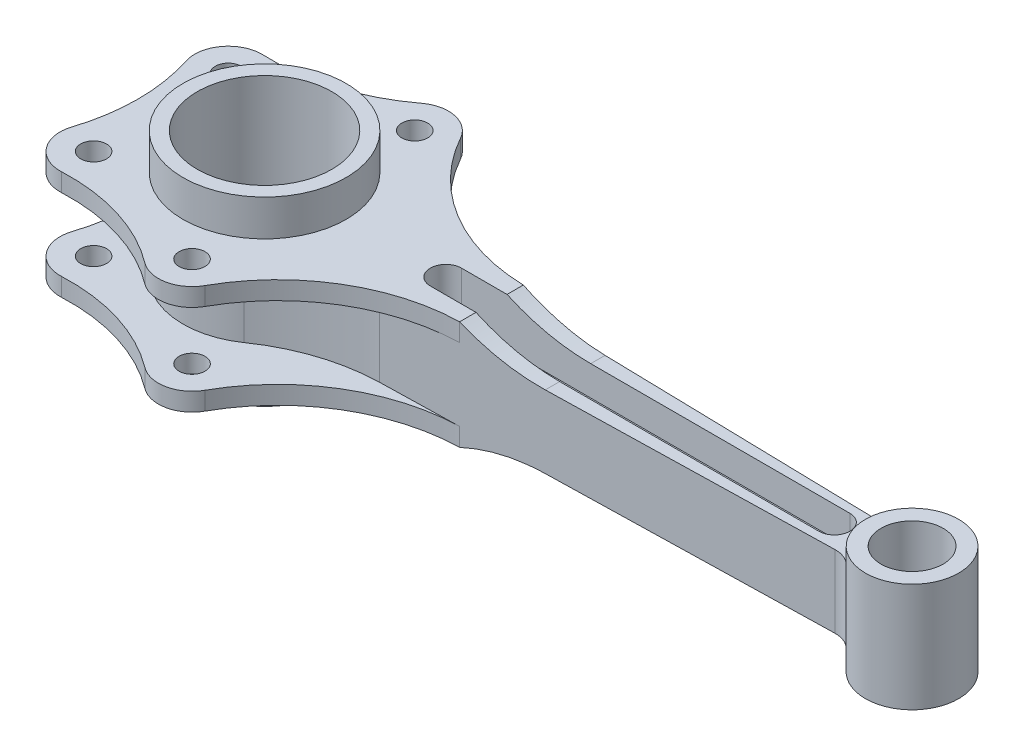
from build123d import *

# Parameters (mm, degrees)
SKETCH1_R           = 31.5
SKETCH1_R_2         = 26
BOSS_EXTRUDE1_DEPTH = 35
SKETCH1_3_R         = 18
SKETCH1_3_R_2       = 12
BOSS_EXTRUDE2_DEPTH = 21
BOSS_EXTRUDE3_DEPTH = 17.5
BOSS_EXTRUDE4_DEPTH = 14
SKETCH3_R           = 5
BOSS_EXTRUDE5_DEPTH = 7
BOSS_EXTRUDE6_REACH = 58
BOSS_EXTRUDE9_REACH = 58
SKETCH6_R           = 26
CUT_EXTRUDE1_DEPTH  = 42
CUT_EXTRUDE2_DEPTH  = 23


with BuildPart() as part:
    # Sketch1 → Boss-Extrude1 (new body, symmetric)
    with BuildSketch(Plane(origin=(0, 0, 0), x_dir=(1, 0, 0), z_dir=(0, 1, 0))):
        Circle(SKETCH1_R)
        Circle(SKETCH1_R_2, mode=Mode.SUBTRACT)
    extrude(amount=BOSS_EXTRUDE1_DEPTH, both=True)

    # Sketch1_5 → Boss-Extrude3 (add, symmetric)
    with BuildSketch(Plane(origin=(0, 0, 0), x_dir=(1, 0, 0), z_dir=(0, 1, 0))):
        with BuildLine():
            ThreePointArc((17.981178031, -25.863627677), (36.746938107, -16.532049941), (57.405028955, -13))
            Line((57.405028955, -13), (87, -12.310914466))
            Line((87, -12.310914466), (87, 12.310914466))
            Line((87, 12.310914466), (57.405028955, 13))
            ThreePointArc((57.405028955, 13), (36.746938107, 16.532049941), (17.981178031, 25.863627677))
            ThreePointArc((17.981178031, 25.863627677), (27.916456688, 14.591828056), (31.5, 0))
            ThreePointArc((31.5, 0), (27.916456688, -14.591828056), (17.981178031, -25.863627677))
        make_face()
    extrude(amount=BOSS_EXTRUDE3_DEPTH, both=True)



with BuildPart() as body_2:
    # Sketch1_3 → Boss-Extrude2 (new body, symmetric)
    with BuildSketch(Plane(origin=(0, 0, 0), x_dir=(1, 0, 0), z_dir=(0, 1, 0))):
        with Locations((250, 0)):
            Circle(SKETCH1_3_R)
        with Locations((250, 0)):
            Circle(SKETCH1_3_R_2, mode=Mode.SUBTRACT)
    extrude(amount=BOSS_EXTRUDE2_DEPTH, both=True)


with BuildPart() as part_1:
    add(part.part)

    add(body_2.part)  # Boss-Extrude4 merges body 2
    # Sketch1_6 → Boss-Extrude4 (add, symmetric)
    with BuildSketch(Plane(origin=(0, 0, 0), x_dir=(1, 0, 0), z_dir=(0, 1, 0))):
        with BuildLine():
            Line((87, 12.310914466), (87, -12.310914466))
            Line((87, -12.310914466), (229.197757742, -9))
            ThreePointArc((229.197757742, -9), (233.333153837, -9.790252147), (236.776771457, -12.212543834))
            ThreePointArc((236.776771457, -12.212543834), (232, 0), (236.776771457, 12.212543834))
            ThreePointArc((236.776771457, 12.212543834), (233.333153837, 9.790252147), (229.197757742, 9))
            Line((229.197757742, 9), (87, 12.310914466))
        make_face()
    extrude(amount=BOSS_EXTRUDE4_DEPTH, both=True)

    # Sketch3 → Boss-Extrude5 (add)
    with BuildSketch(Plane(origin=(0, 14, 0), x_dir=(1, 0, 0), z_dir=(0, 1, 0))):
        with BuildLine():
            Line((87.628988844, 12.29626917), (87.628988844, -12.29626917))
            ThreePointArc((87.628988844, -12.29626917), (52.070762211, -22.651980063), (26.364290052, -49.312916252))
            ThreePointArc((26.364290052, -49.312916252), (17.700433018, -55.716432735), (7.181946677, -53.386435492))
            ThreePointArc((7.181946677, -53.386435492), (-14.855989459, -42.122318837), (-39.406288617, -38.986435492))
            ThreePointArc((-39.406288617, -38.986435492), (-50.326951915, -33.896458963), (-52.376901133, -22.023529412))
            ThreePointArc((-52.376901133, -22.023529412), (-48.925892025, 0), (-52.376901133, 22.023529412))
            ThreePointArc((-52.376901133, 22.023529412), (-50.326951915, 33.896458963), (-39.406288617, 38.986435492))
            ThreePointArc((-39.406288617, 38.986435492), (-14.855989459, 42.122318837), (7.181946677, 53.386435492))
            ThreePointArc((7.181946677, 53.386435492), (17.700433018, 55.716432735), (26.364290052, 49.312916252))
            ThreePointArc((26.364290052, 49.312916252), (52.070762211, 22.651980063), (87.628988844, 12.29626917))
        make_face()
        with Locations((15, 43)):
            Circle(SKETCH3_R, mode=Mode.SUBTRACT)
        with Locations((-40, 26)):
            Circle(SKETCH3_R, mode=Mode.SUBTRACT)
        with Locations((-40, -26)):
            Circle(SKETCH3_R, mode=Mode.SUBTRACT)
        with Locations((15, -43)):
            Circle(SKETCH3_R, mode=Mode.SUBTRACT)
    boss_extrude5 = extrude(amount=BOSS_EXTRUDE5_DEPTH)

    # Mirror1: Boss-Extrude5 across plane
    add(boss_extrude5.mirror(Plane.ZX))

    # Boss-Extrude6: up to this face of the body (flat: up to its plane)
    boss_extrude6_end = Plane(part_1.part.faces().sort_by_distance((143.301393348, 0, 11))[0])
    # Sketch4 → Boss-Extrude6 (add, up to the picked face)
    with BuildSketch(Plane.XY, mode=Mode.PRIVATE) as boss_extrude6_sk1:
        with BuildLine():
            Line((87.628988844, 21), (87.628988844, 14))
            Line((87.628988844, 14), (119.924499368, 14))
            ThreePointArc((119.924499368, 14), (103.401787726, 15.770084612), (87.628988844, 21))
        make_face()
    boss_extrude6_tool1 = split(extrude(boss_extrude6_sk1.sketch, amount=BOSS_EXTRUDE6_REACH, mode=Mode.PRIVATE), bisect_by=boss_extrude6_end, keep=Keep.BOTH, mode=Mode.PRIVATE)
    add(boss_extrude6_tool1.solids().sort_by_distance((95.628627, 16.082796, 0))[0])
    # Sketch4 → Boss-Extrude6 (add, up to the picked face)
    with BuildSketch(Plane.XY, mode=Mode.PRIVATE) as boss_extrude6_sk2:
        with BuildLine():
            Line((87.628988844, -21), (87.628988844, -14))
            Line((87.628988844, -14), (119.924499368, -14))
            ThreePointArc((119.924499368, -14), (103.401787726, -15.770084612), (87.628988844, -21))
        make_face()
    boss_extrude6_tool2 = split(extrude(boss_extrude6_sk2.sketch, amount=BOSS_EXTRUDE6_REACH, mode=Mode.PRIVATE), bisect_by=boss_extrude6_end, keep=Keep.BOTH, mode=Mode.PRIVATE)
    add(boss_extrude6_tool2.solids().sort_by_distance((95.628627, -16.082796, 0))[0])

    # Boss-Extrude9: up to this face of the body (flat: up to its plane)
    boss_extrude9_end = Plane(part_1.part.faces().sort_by_distance((143.301393348, 0, -11))[0])
    # Sketch5 → Boss-Extrude9 (add, up to the picked face)
    with BuildSketch(Plane(origin=(0, 0, 0), x_dir=(-1, 0, 0), z_dir=(0, 0, -1)), mode=Mode.PRIVATE) as boss_extrude9_sk1:
        with BuildLine():
            Line((-119.924499368, -14), (-87.628988844, -14))
            Line((-87.628988844, -14), (-87.628988844, -21))
            ThreePointArc((-87.628988844, -21), (-103.401787726, -15.770084612), (-119.924499368, -14))
        make_face()
    boss_extrude9_tool1 = split(extrude(boss_extrude9_sk1.sketch, amount=BOSS_EXTRUDE9_REACH, mode=Mode.PRIVATE), bisect_by=boss_extrude9_end, keep=Keep.BOTH, mode=Mode.PRIVATE)
    add(boss_extrude9_tool1.solids().sort_by_distance((95.628627, -16.082796, 0))[0])
    # Sketch5 → Boss-Extrude9 (add, up to the picked face)
    with BuildSketch(Plane(origin=(0, 0, 0), x_dir=(-1, 0, 0), z_dir=(0, 0, -1)), mode=Mode.PRIVATE) as boss_extrude9_sk2:
        with BuildLine():
            Line((-119.924499368, 14), (-87.628988844, 14))
            Line((-87.628988844, 14), (-87.628988844, 21))
            ThreePointArc((-87.628988844, 21), (-103.401787726, 15.770084612), (-119.924499368, 14))
        make_face()
    boss_extrude9_tool2 = split(extrude(boss_extrude9_sk2.sketch, amount=BOSS_EXTRUDE9_REACH, mode=Mode.PRIVATE), bisect_by=boss_extrude9_end, keep=Keep.BOTH, mode=Mode.PRIVATE)
    add(boss_extrude9_tool2.solids().sort_by_distance((95.628627, 16.082796, 0))[0])

    # Sketch6 → Cut-Extrude1 (cut)
    with BuildSketch(Plane(origin=(0, 21, 0), x_dir=(1, 0, 0), z_dir=(0, 1, 0))):
        Circle(SKETCH6_R)
    extrude(amount=-CUT_EXTRUDE1_DEPTH, mode=Mode.SUBTRACT)

    # Sketch7 → Cut-Extrude2 (cut)
    with BuildSketch(Plane(origin=(0, 2.5, 0), x_dir=(1, 0, 0), z_dir=(0, 1, 0))):
        with BuildLine():
            Line((220, -6), (70, -6))
            ThreePointArc((70, -6), (64, 0), (70, 6))
            Line((70, 6), (220, 6))
            ThreePointArc((220, 6), (226, 0), (220, -6))
        make_face()
    cut_extrude2 = extrude(amount=CUT_EXTRUDE2_DEPTH, mode=Mode.SUBTRACT)

    # Mirror2: Cut-Extrude2 across plane
    add(cut_extrude2.mirror(Plane.ZX), mode=Mode.SUBTRACT)


solid = part_1.part
